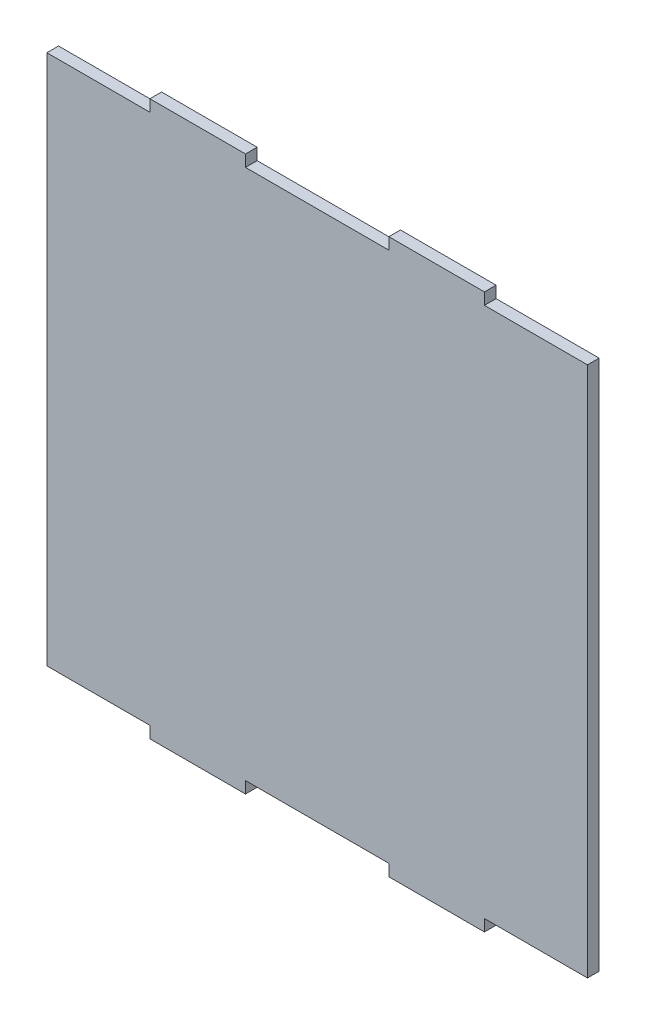
from build123d import *

# Parameters (mm, degrees)
SALIENTE_EXTRUIR1_DEPTH = 2.44


with BuildPart() as part:
    # Croquis1 → Saliente-Extruir1 (new body)
    with BuildSketch(Plane.XY):
        Polygon((-56.56, -55.56), (-35, -55.56), (-35, -58), (-15, -58), (-15, -55.56), (15, -55.56), (15, -58), (35, -58), (35, -55.56), (56.56, -55.56), (56.56, 55.56), (35, 55.56), (35, 58), (15, 58), (15, 55.56), (-15, 55.56), (-15, 58), (-35, 58), (-35, 55.56), (-56.56, 55.56), align=None)
    extrude(amount=SALIENTE_EXTRUIR1_DEPTH)


solid = part.part
